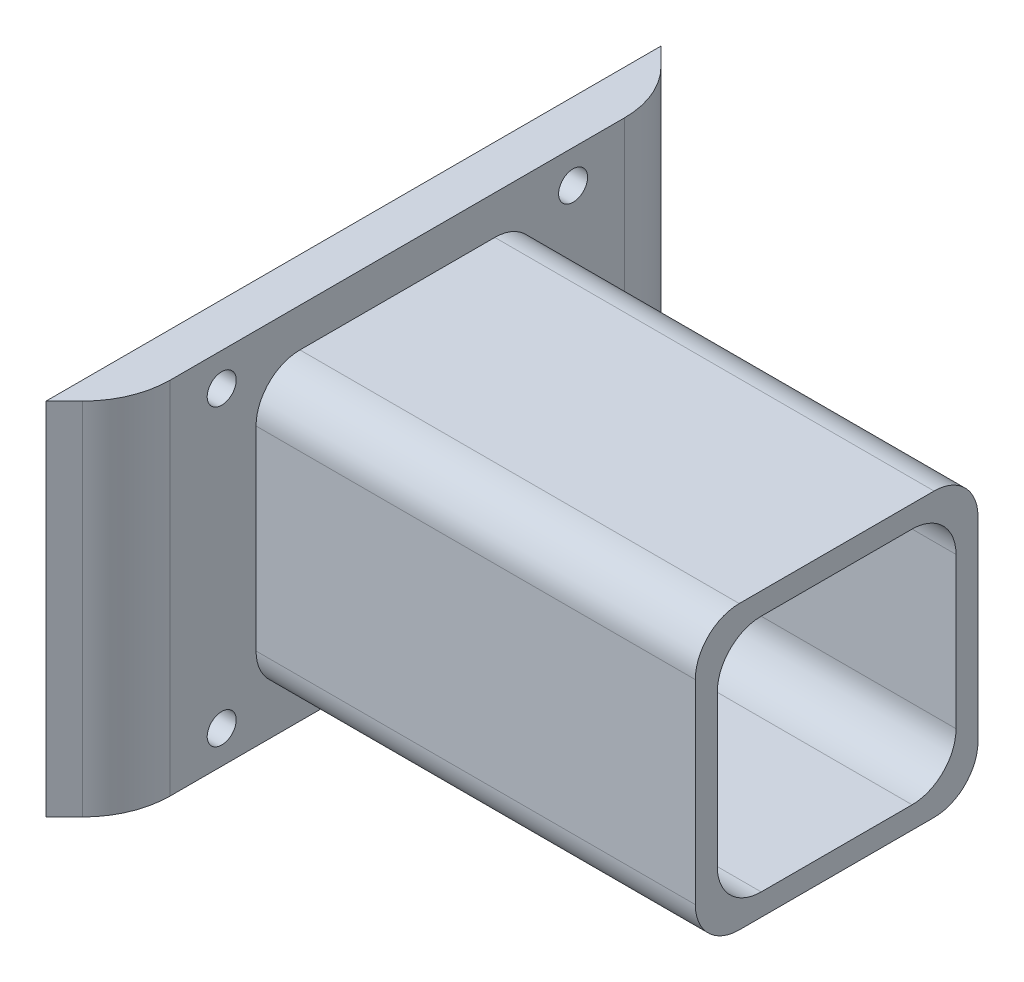
from build123d import *

# Parameters (mm, degrees)
SKETCH1_W                = 120
SKETCH1_H                = 82
BOSS_EXTRUDE1_DEPTH      = 10
BOSS_EXTRUDE4_DEPTH      = 82
FILLET2_R                = 20
BOSS_EXTRUDE5_DEPTH      = 100
M6_CLEARANCE_HOLE1_D     = 6.6
M6_CLEARANCE_HOLE1_DEPTH = 10


with BuildPart() as part:
    # Sketch1 → Boss-Extrude1 (new body)
    with BuildSketch(Plane(origin=(0, 0, 0), x_dir=(0, 0, -1), z_dir=(1, 0, 0))):
        Rectangle(SKETCH1_W, SKETCH1_H)
    extrude(amount=BOSS_EXTRUDE1_DEPTH)

    # Sketch6 → Boss-Extrude4 (add)
    with BuildSketch(Plane(origin=(0, 41, 0), x_dir=(1, 0, 0), z_dir=(0, 1, 0))):
        Polygon((0, 60), (0, 70), (10, 60), align=None)
        Polygon((0, -60), (0, -70), (10, -60), align=None)
    extrude(amount=-BOSS_EXTRUDE4_DEPTH)

    # Fillet2
    fillet2_edges = [part.edges().sort_by_distance(p)[0] for p in [
        (10, 0, 60),
        (10, 0, -60),
    ]]
    fillet(fillet2_edges, radius=FILLET2_R)

    # Sketch7 → Boss-Extrude5 (add)
    with BuildSketch(Plane(origin=(10, 0, 0), x_dir=(0, 0, -1), z_dir=(1, 0, 0))):
        with BuildLine():
            Line((-22.18, -32.18), (22.18, -32.18))
            ThreePointArc((22.18, -32.18), (29.251067812, -29.251067812), (32.18, -22.18))
            Line((32.18, -22.18), (32.18, 22.18))
            ThreePointArc((32.18, 22.18), (29.251067812, 29.251067812), (22.18, 32.18))
            Line((22.18, 32.18), (-22.18, 32.18))
            ThreePointArc((-22.18, 32.18), (-29.251067812, 29.251067812), (-32.18, 22.18))
            Line((-32.18, 22.18), (-32.18, -22.18))
            ThreePointArc((-32.18, -22.18), (-29.251067812, -29.251067812), (-22.18, -32.18))
        make_face()
        with BuildLine():
            Line((-17.18, -27.18), (17.18, -27.18))
            ThreePointArc((17.18, -27.18), (24.251067812, -24.251067812), (27.18, -17.18))
            Line((27.18, -17.18), (27.18, 17.18))
            ThreePointArc((27.18, 17.18), (24.251067812, 24.251067812), (17.18, 27.18))
            Line((17.18, 27.18), (-17.18, 27.18))
            ThreePointArc((-17.18, 27.18), (-24.251067812, 24.251067812), (-27.18, 17.18))
            Line((-27.18, 17.18), (-27.18, -17.18))
            ThreePointArc((-27.18, -17.18), (-24.251067812, -24.251067812), (-17.18, -27.18))
        make_face(mode=Mode.SUBTRACT)
    extrude(amount=BOSS_EXTRUDE5_DEPTH)

    # M6 Clearance Hole1
    with Locations(Plane(origin=(10, 0, 0), x_dir=(0, 0, -1), z_dir=(1, 0, 0))):
        with Locations((-40, 33.5), (40, 33.5), (40, -33.5), (-40, -33.5)):
            Hole(M6_CLEARANCE_HOLE1_D / 2, depth=M6_CLEARANCE_HOLE1_DEPTH)


solid = part.part
